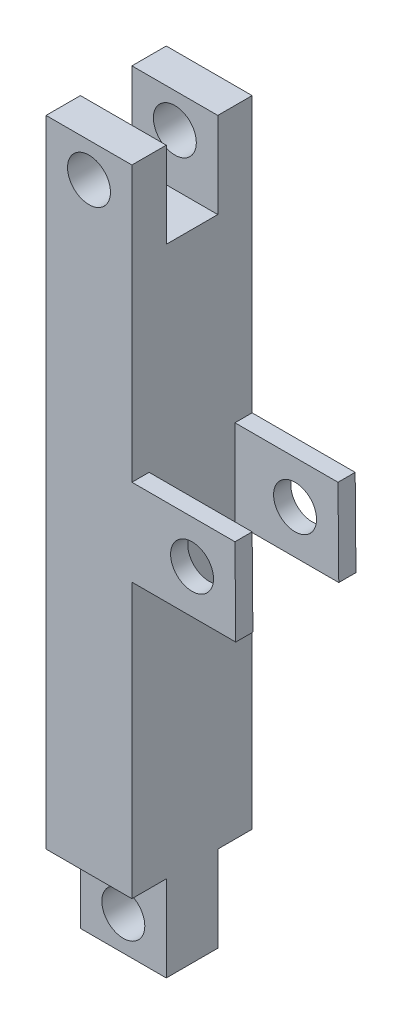
from build123d import *

# Parameters (mm, degrees)
SKETCH_1_W                = 10
SKETCH_1_H                = 14
EXTRUDE_1_DEPTH           = 37
EXTRUDE_3_DEPTH           = 7
SKETCH_8_W                = 12.090263245
SKETCH_8_H                = 10.07196207
CUT_EXTRUDE_3_DEPTH       = 5
SKETCH_10_R               = 2.5
CUT_EXTRUDE_4_DEPTH       = 8
CUT_EXTRUDE_4_DEPTH_BACK  = 8
SKETCH_14_W               = 10
SKETCH_14_H               = 10
CUT_EXTRUDE_8_DEPTH       = 3
SKETCH_15_W               = 10
SKETCH_15_H               = 10
EXTRUDE_4_DEPTH           = 3
SKETCH_16_R               = 2.5
CUT_EXTRUDE_9_DEPTH       = 8
CUT_EXTRUDE_9_DEPTH_BACK  = 8
SKETCH_17_R               = 2.5
CUT_EXTRUDE_10_DEPTH      = 8
CUT_EXTRUDE_10_DEPTH_BACK = 8


with BuildPart() as part:
    # 草图1 → 凸台-拉伸1 (new body, symmetric)
    with BuildSketch(Plane(origin=(0, 0, 0), x_dir=(1, 0, 0), z_dir=(0, 1, 0))):
        Rectangle(SKETCH_1_W, SKETCH_1_H)
    extrude(amount=EXTRUDE_1_DEPTH, both=True)

    # 草图7 → 凸台-拉伸3 (add, symmetric)
    with BuildSketch(Plane.XY):
        Polygon((5, 5), (17, 5), (17.090263245, -5.07196207), (5, -5.07196207), align=None)
    extrude(amount=EXTRUDE_3_DEPTH, both=True)

    # 草图8 → 切除-拉伸3 (cut, symmetric)
    with BuildSketch(Plane.XY):
        with Locations((11.045131623, -0.035981035)):
            Rectangle(SKETCH_8_W, SKETCH_8_H)
    extrude(amount=CUT_EXTRUDE_3_DEPTH, both=True, mode=Mode.SUBTRACT)

    # 草图10 → 切除-拉伸4 (cut, two sides)
    with BuildSketch(Plane.XY) as cut_extrude_4_sk:
        with Locations((12, 0)):
            Circle(SKETCH_10_R)
    extrude(amount=CUT_EXTRUDE_4_DEPTH, mode=Mode.SUBTRACT)
    extrude(cut_extrude_4_sk.sketch, amount=-CUT_EXTRUDE_4_DEPTH_BACK, mode=Mode.SUBTRACT)

    # 草图14 → 切除-拉伸8 (cut, symmetric)
    with BuildSketch(Plane.XY):
        with Locations((0, 32)):
            Rectangle(SKETCH_14_W, SKETCH_14_H)
    extrude(amount=CUT_EXTRUDE_8_DEPTH, both=True, mode=Mode.SUBTRACT)

    # 草图15 → 凸台-拉伸4 (add, symmetric)
    with BuildSketch(Plane.XY):
        with Locations((0, -42)):
            Rectangle(SKETCH_15_W, SKETCH_15_H)
    extrude(amount=EXTRUDE_4_DEPTH, both=True)

    # 草图16 → 切除-拉伸9 (cut, two sides)
    with BuildSketch(Plane.XY) as cut_extrude_9_sk:
        with Locations((0, 33)):
            Circle(SKETCH_16_R)
    extrude(amount=CUT_EXTRUDE_9_DEPTH, mode=Mode.SUBTRACT)
    extrude(cut_extrude_9_sk.sketch, amount=-CUT_EXTRUDE_9_DEPTH_BACK, mode=Mode.SUBTRACT)

    # 草图17 → 切除-拉伸10 (cut, two sides)
    with BuildSketch(Plane.XY) as cut_extrude_10_sk:
        with Locations((0, -43)):
            Circle(SKETCH_17_R)
    extrude(amount=CUT_EXTRUDE_10_DEPTH, mode=Mode.SUBTRACT)
    extrude(cut_extrude_10_sk.sketch, amount=-CUT_EXTRUDE_10_DEPTH_BACK, mode=Mode.SUBTRACT)


solid = part.part
